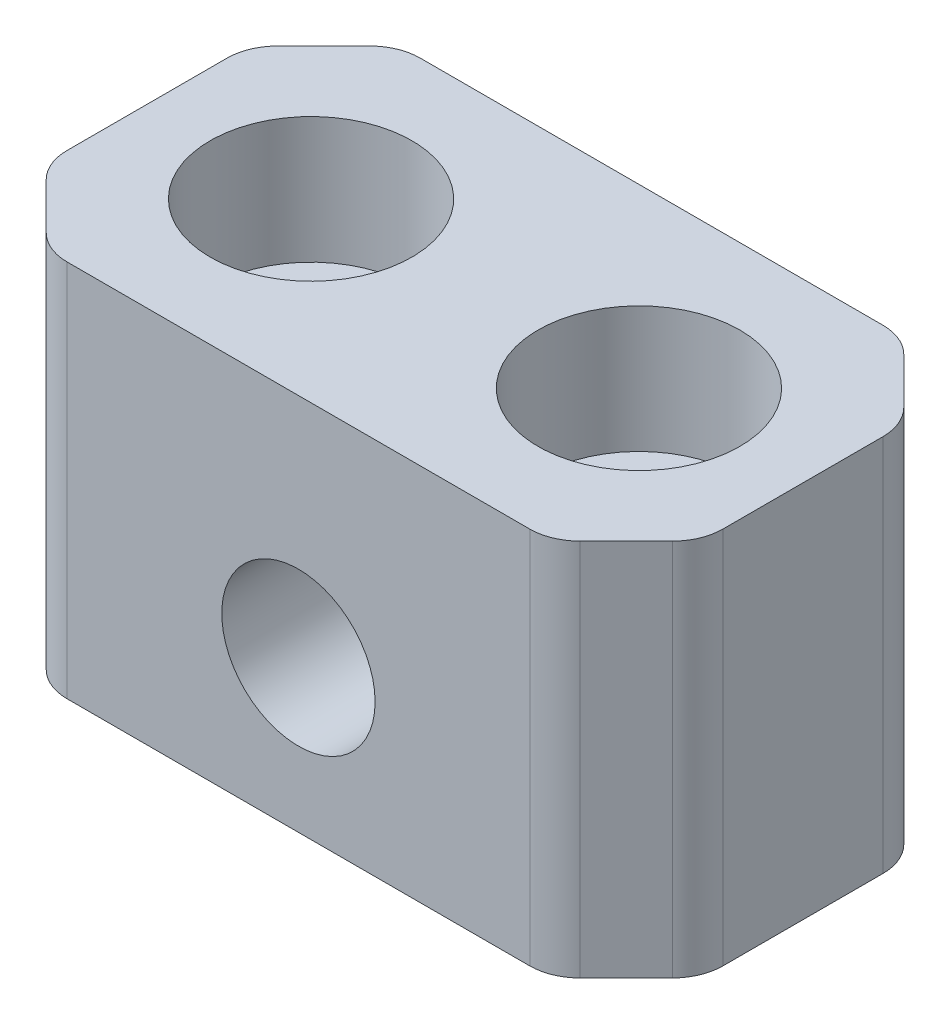
from build123d import *

# Parameters (mm, degrees)
BOSS_EXTRUDE1_DEPTH      = 7
BOSS_EXTRUDE1_DEPTH_BACK = 7
SKETCH1_W                = 26
SKETCH1_H                = 15
CUT_EXTRUDE1_DEPTH       = 7
CUT_EXTRUDE1_DEPTH_BACK  = 7
SKETCH3_R                = 3.04
SKETCH4_R                = 4
CUT_EXTRUDE2_DEPTH       = 5
CHAMFER1_SIZE            = 3
FILLET1_R                = 2
ESQUISSE1_R              = 2.75
ENL_V_MAT_EXTRU_1_DEPTH  = 10
ESQUISSE2_R              = 2.75
ENL_V_MAT_EXTRU_2_DEPTH  = 10


with BuildPart() as part:
    # Sketch1 → Boss-Extrude1 (new, two sides: drawn at the far end of the back side and taken through both)
    with BuildSketch(Plane.XY.offset(-BOSS_EXTRUDE1_DEPTH_BACK)):
        Rectangle(SKETCH1_W, SKETCH1_H)
    extrude(amount=BOSS_EXTRUDE1_DEPTH + BOSS_EXTRUDE1_DEPTH_BACK)

    # Sketch3 → Cut-Extrude1 (cut, two sides: drawn at the far end of the back side and taken through both)
    with BuildSketch(Plane.XY.offset(-CUT_EXTRUDE1_DEPTH_BACK)):
        with Locations((0, -1.5)):
            Circle(SKETCH3_R)
    extrude(amount=CUT_EXTRUDE1_DEPTH + CUT_EXTRUDE1_DEPTH_BACK, mode=Mode.SUBTRACT)

    # Sketch4 → Cut-Extrude2 (cut)
    with BuildSketch(Plane(origin=(0, 7.5, 0), x_dir=(1, 0, 0), z_dir=(0, 1, 0))):
        with Locations((-6.5, 0)):
            Circle(SKETCH4_R)
        with Locations((6.5, 0)):
            Circle(SKETCH4_R)
    extrude(amount=-CUT_EXTRUDE2_DEPTH, mode=Mode.SUBTRACT)

    # Chamfer1
    chamfer1_edges = [part.edges().sort_by_distance(p)[0] for p in [
        (13, 0, -7),
        (13, 0, 7),
        (-13, 0, -7),
        (-13, 0, 7),
    ]]
    chamfer(chamfer1_edges, length=CHAMFER1_SIZE)

    # Fillet1
    fillet1_edges = [part.edges().sort_by_distance(p)[0] for p in [
        (-10, 0, -7),
        (-13, 0, -4),
        (10, 0, -7),
        (13, 0, -4),
        (13, 0, 4),
        (10, 0, 7),
        (-13, 0, 4),
        (-10, 0, 7),
    ]]
    fillet(fillet1_edges, radius=FILLET1_R)

    # Esquisse1 → Enlèv. mat.-Extru.1 (cut)
    with BuildSketch(Plane(origin=(0, 2.5, 0), x_dir=(1, 0, 0), z_dir=(0, 1, 0))):
        with Locations((6.5, 0)):
            Circle(ESQUISSE1_R)
    extrude(amount=-ENL_V_MAT_EXTRU_1_DEPTH, mode=Mode.SUBTRACT)

    # Esquisse2 → Enlèv. mat.-Extru.2 (cut)
    with BuildSketch(Plane(origin=(0, 2.5, 0), x_dir=(1, 0, 0), z_dir=(0, 1, 0))):
        with Locations((-6.5, 0)):
            Circle(ESQUISSE2_R)
    extrude(amount=-ENL_V_MAT_EXTRU_2_DEPTH, mode=Mode.SUBTRACT)


solid = part.part
